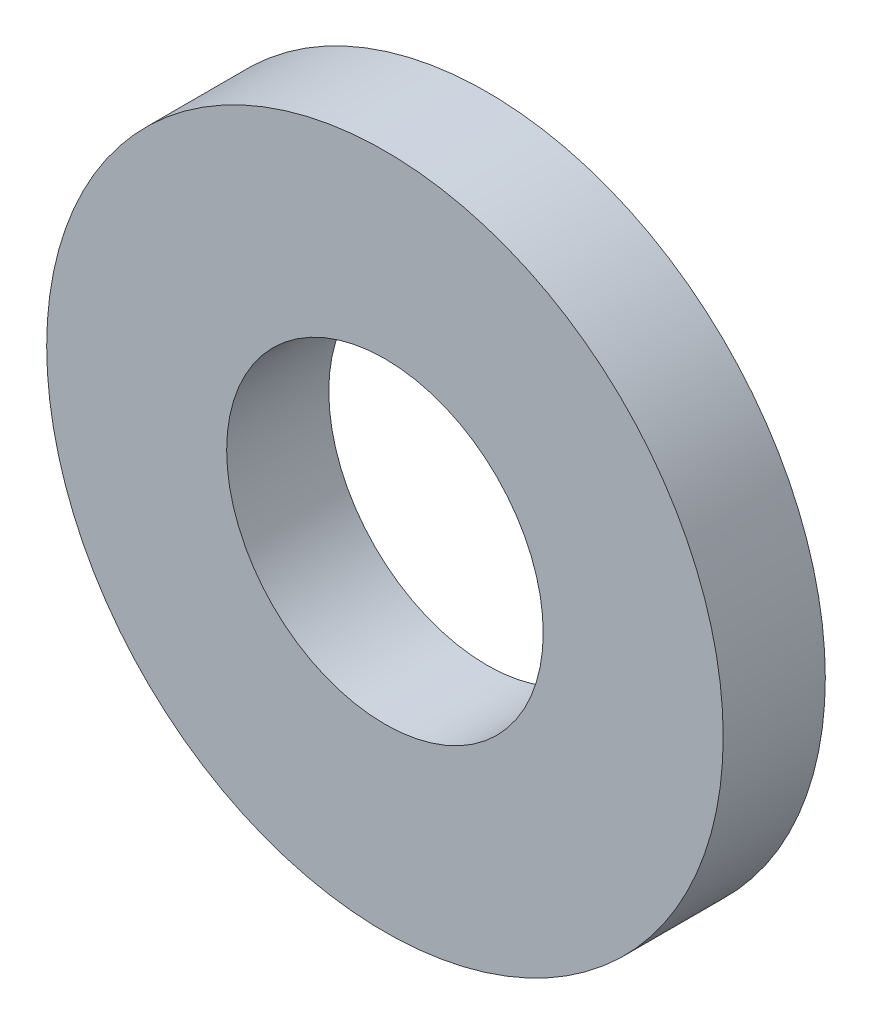
from build123d import *

# Parameters (mm, degrees)
SKETCH1_R           = 66.25
SKETCH1_R_2         = 25
BOSS_EXTRUDE1_DEPTH = 20
SKETCH4_R           = 31
CUT_EXTRUDE2_DEPTH  = 21


with BuildPart() as part:
    # Sketch1 → Boss-Extrude1 (new body)
    with BuildSketch(Plane.XY):
        Circle(SKETCH1_R)
        Circle(SKETCH1_R_2, mode=Mode.SUBTRACT)
    extrude(amount=BOSS_EXTRUDE1_DEPTH)

    # Sketch4 → Cut-Extrude2 (cut, through all)
    with BuildSketch(Plane.XY.offset(20)):
        Circle(SKETCH4_R)
    extrude(amount=-CUT_EXTRUDE2_DEPTH, mode=Mode.SUBTRACT)


solid = part.part
